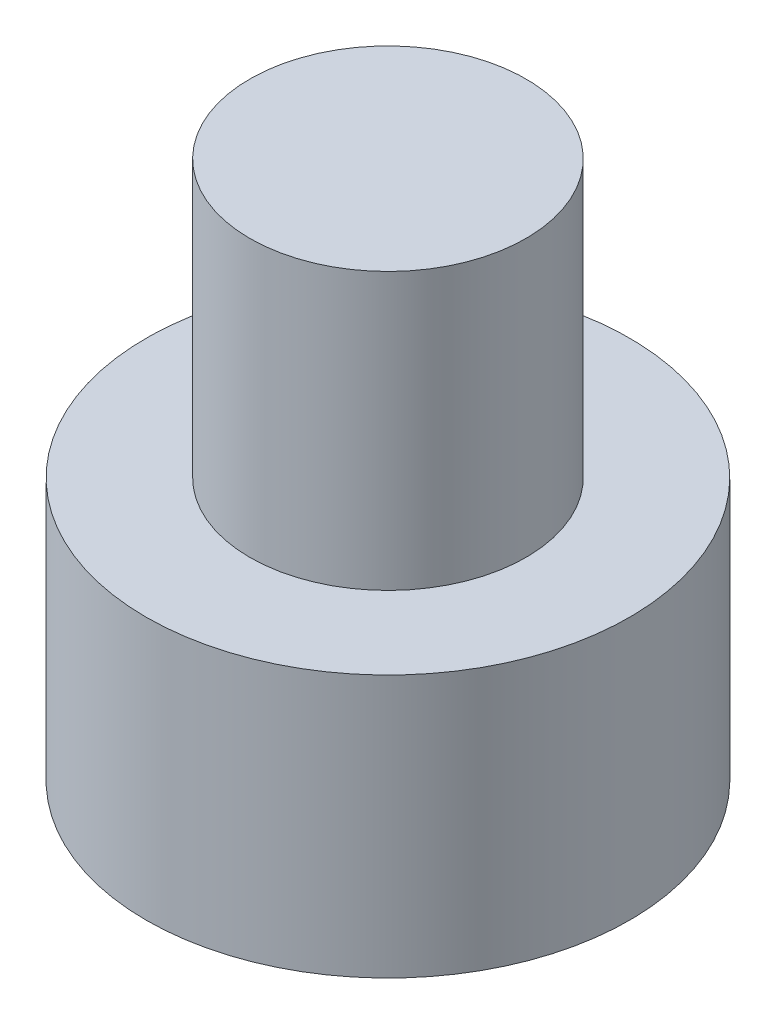
from build123d import *


with BuildPart() as part:
    # Esquisse1 → Révolution1 (revolve)
    with BuildSketch(Plane.XY, mode=Mode.PRIVATE) as r_volution1_sk:
        Polygon((0, -3.9), (3.5, -3.9), (3.5, -0.1), (2, -0.1), (2, 3.9), (0, 3.9), align=None)
    revolve(r_volution1_sk.sketch.rotate(Axis((0, 3.9, 0), (0, -1, 0)), 90), axis=Axis((0, 3.9, 0), (0, -1, 0)))  # turned: the seam where the file's is


solid = part.part
